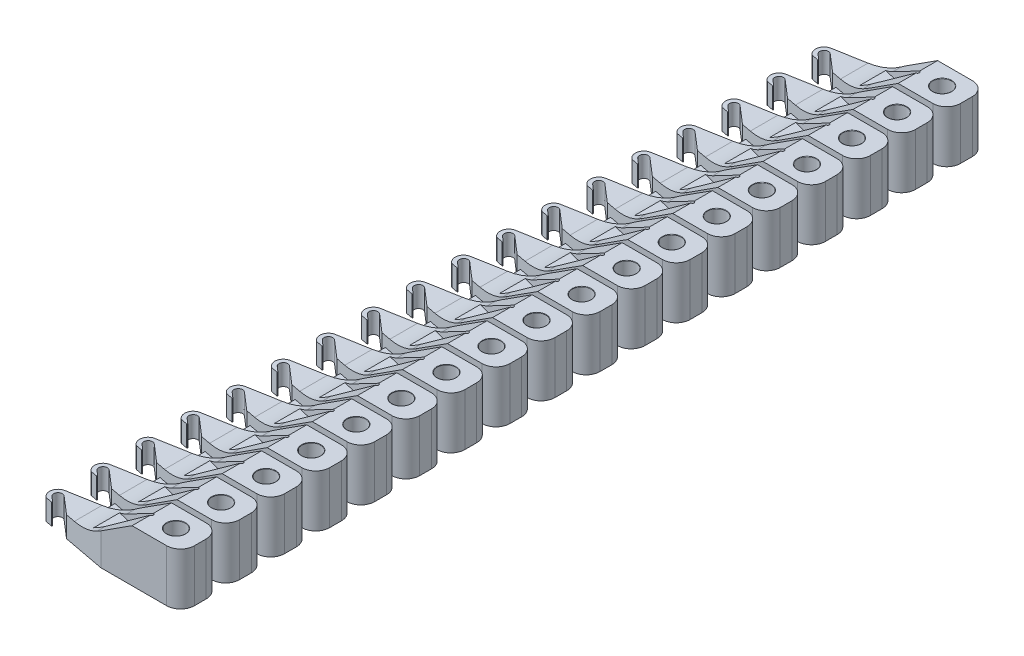
from build123d import *

# Parameters (mm, degrees)
SKETCH1_R               = 0.27
BOSS_EXTRUDE1_DEPTH     = 1.5
CUT_EXTRUDE1_DEPTH      = 1.57
CUT_EXTRUDE1_DEPTH_BACK = 1.57
FILLET1_R               = 0.01
FILLET2_R               = 1.5
FILLET3_R               = 0.4
CUT_EXTRUDE2_DEPTH      = 0.8
FILLET4_R               = 0.05
LPATTERN2_COUNT         = 18
LPATTERN2_PITCH         = 1.3
BOSS_EXTRUDE2_START     = -21.737265
SKETCH3_W               = 0.7
SKETCH3_H               = 0.3
BOSS_EXTRUDE2_DEPTH     = 21.36284


with BuildPart() as part:
    # Sketch1 → Boss-Extrude1 (new body)
    with BuildSketch(Plane(origin=(0, 0, 0), x_dir=(1, 0, 0), z_dir=(0, 1, 0))):
        with BuildLine():
            Line((0.7, -0.57), (0.7, 0.57))
            Line((0.7, 0.57), (-1.6, 0.57))
            Line((-1.6, 0.57), (-3.447847995, 0.241461235))
            ThreePointArc((-3.447847995, 0.241461235), (-3.645035502, 0.049898187), (-3.54049396, -0.204366204))
            Line((-3.54049396, -0.204366204), (-3.353011522, -0.239692217))
            ThreePointArc((-3.353011522, -0.239692217), (-3.347007702, -0.238312918), (-3.34104042, -0.236783261))
            Line((-3.34104042, -0.236783261), (-3.34104042, -0.220416717))
            Line((-3.34104042, -0.220416717), (-3.486679159, -0.094774919))
            ThreePointArc((-3.486679159, -0.094774919), (-3.499692238, 0.08176184), (-3.323155479, 0.094774919))
            Line((-3.323155479, 0.094774919), (-2.818770339, -0.340355572))
            Line((-2.818770339, -0.340355572), (-1.6, -0.57))
            Line((-1.6, -0.57), (0.7, -0.57))
        make_face()
        Circle(SKETCH1_R, mode=Mode.SUBTRACT)
    extrude(amount=BOSS_EXTRUDE1_DEPTH)

    # Sketch2 → Cut-Extrude1 (cut, two sides)
    with BuildSketch(Plane.XY) as cut_extrude1_sk:
        Polygon((-4.254461252, 0.6), (-2.1, 0.6), (-0.7, 1.5), (-4.254461252, 1.5), align=None)
    extrude(amount=CUT_EXTRUDE1_DEPTH, mode=Mode.SUBTRACT)
    extrude(cut_extrude1_sk.sketch, amount=-CUT_EXTRUDE1_DEPTH_BACK, mode=Mode.SUBTRACT)

    # Fillet1
    fillet1_edges = [part.edges().sort_by_distance(p)[0] for p in [
        (-0.27, 0, 0),
        (-0.27, 1.5, 0),
    ]]
    fillet(fillet1_edges, radius=FILLET1_R)

    # Fillet2
    fillet2_edges = [part.edges().sort_by_distance(p)[0] for p in [
        (-2.1, 0.6, -0.002656928),
    ]]
    fillet(fillet2_edges, radius=FILLET2_R)

    # Fillet3
    fillet3_edges = [part.edges().sort_by_distance(p)[0] for p in [
        (0.7, 0.75, -0.57),
        (0.7, 0.75, 0.57),
    ]]
    fillet(fillet3_edges, radius=FILLET3_R)

    # Sketch4 → Cut-Extrude2 (cut)
    with BuildSketch(Plane(origin=(0, 1.5, 0), x_dir=(1, 0, 0), z_dir=(0, 1, 0))):
        Polygon((-0.5, 0), (-2.5, 0.5), (-2.5, -0.5), align=None)
    extrude(amount=-CUT_EXTRUDE2_DEPTH, mode=Mode.SUBTRACT)

    # Fillet4
    fillet4_edges = [part.edges().sort_by_distance(p)[0] for p in [
        (-0.5, 1.1, 0),
    ]]
    fillet(fillet4_edges, radius=FILLET4_R)


with BuildPart() as lpattern2_1:
    # LPattern2: pattern copy
    add(part.part.moved(Location(Vector(0, 0, -1) * (1 * LPATTERN2_PITCH))))


with BuildPart() as lpattern2_2:
    # LPattern2: pattern copy
    add(part.part.moved(Location(Vector(0, 0, -1) * (2 * LPATTERN2_PITCH))))


with BuildPart() as lpattern2_3:
    # LPattern2: pattern copy
    add(part.part.moved(Location(Vector(0, 0, -1) * (3 * LPATTERN2_PITCH))))


with BuildPart() as lpattern2_4:
    # LPattern2: pattern copy
    add(part.part.moved(Location(Vector(0, 0, -1) * (4 * LPATTERN2_PITCH))))


with BuildPart() as lpattern2_5:
    # LPattern2: pattern copy
    add(part.part.moved(Location(Vector(0, 0, -1) * (5 * LPATTERN2_PITCH))))


with BuildPart() as lpattern2_6:
    # LPattern2: pattern copy
    add(part.part.moved(Location(Vector(0, 0, -1) * (6 * LPATTERN2_PITCH))))


with BuildPart() as lpattern2_7:
    # LPattern2: pattern copy
    add(part.part.moved(Location(Vector(0, 0, -1) * (7 * LPATTERN2_PITCH))))


with BuildPart() as lpattern2_8:
    # LPattern2: pattern copy
    add(part.part.moved(Location(Vector(0, 0, -1) * (8 * LPATTERN2_PITCH))))


with BuildPart() as lpattern2_9:
    # LPattern2: pattern copy
    add(part.part.moved(Location(Vector(0, 0, -1) * (9 * LPATTERN2_PITCH))))


with BuildPart() as lpattern2_10:
    # LPattern2: pattern copy
    add(part.part.moved(Location(Vector(0, 0, -1) * (10 * LPATTERN2_PITCH))))


with BuildPart() as lpattern2_11:
    # LPattern2: pattern copy
    add(part.part.moved(Location(Vector(0, 0, -1) * (11 * LPATTERN2_PITCH))))


with BuildPart() as lpattern2_12:
    # LPattern2: pattern copy
    add(part.part.moved(Location(Vector(0, 0, -1) * (12 * LPATTERN2_PITCH))))


with BuildPart() as lpattern2_13:
    # LPattern2: pattern copy
    add(part.part.moved(Location(Vector(0, 0, -1) * (13 * LPATTERN2_PITCH))))


with BuildPart() as lpattern2_14:
    # LPattern2: pattern copy
    add(part.part.moved(Location(Vector(0, 0, -1) * (14 * LPATTERN2_PITCH))))


with BuildPart() as lpattern2_15:
    # LPattern2: pattern copy
    add(part.part.moved(Location(Vector(0, 0, -1) * (15 * LPATTERN2_PITCH))))


with BuildPart() as lpattern2_16:
    # LPattern2: pattern copy
    add(part.part.moved(Location(Vector(0, 0, -1) * (16 * LPATTERN2_PITCH))))


with BuildPart() as lpattern2_17:
    # LPattern2: pattern copy
    add(part.part.moved(Location(Vector(0, 0, -1) * (17 * LPATTERN2_PITCH))))


with BuildPart() as part_1:
    add(part.part)

    add(lpattern2_1.part)  # Boss-Extrude2 merges LPattern2_1

    add(lpattern2_2.part)  # Boss-Extrude2 merges LPattern2_2

    add(lpattern2_3.part)  # Boss-Extrude2 merges LPattern2_3

    add(lpattern2_4.part)  # Boss-Extrude2 merges LPattern2_4

    add(lpattern2_5.part)  # Boss-Extrude2 merges LPattern2_5

    add(lpattern2_6.part)  # Boss-Extrude2 merges LPattern2_6

    add(lpattern2_7.part)  # Boss-Extrude2 merges LPattern2_7

    add(lpattern2_8.part)  # Boss-Extrude2 merges LPattern2_8

    add(lpattern2_9.part)  # Boss-Extrude2 merges LPattern2_9

    add(lpattern2_10.part)  # Boss-Extrude2 merges LPattern2_10

    add(lpattern2_11.part)  # Boss-Extrude2 merges LPattern2_11

    add(lpattern2_12.part)  # Boss-Extrude2 merges LPattern2_12

    add(lpattern2_13.part)  # Boss-Extrude2 merges LPattern2_13

    add(lpattern2_14.part)  # Boss-Extrude2 merges LPattern2_14

    add(lpattern2_15.part)  # Boss-Extrude2 merges LPattern2_15

    add(lpattern2_16.part)  # Boss-Extrude2 merges LPattern2_16

    add(lpattern2_17.part)  # Boss-Extrude2 merges LPattern2_17
    # Sketch3 → Boss-Extrude2 (add)
    with BuildSketch(Plane.XY.offset(BOSS_EXTRUDE2_START)):
        with Locations((-2.35, 0.15)):
            Rectangle(SKETCH3_W, SKETCH3_H)
    extrude(amount=BOSS_EXTRUDE2_DEPTH)


solid = part_1.part
